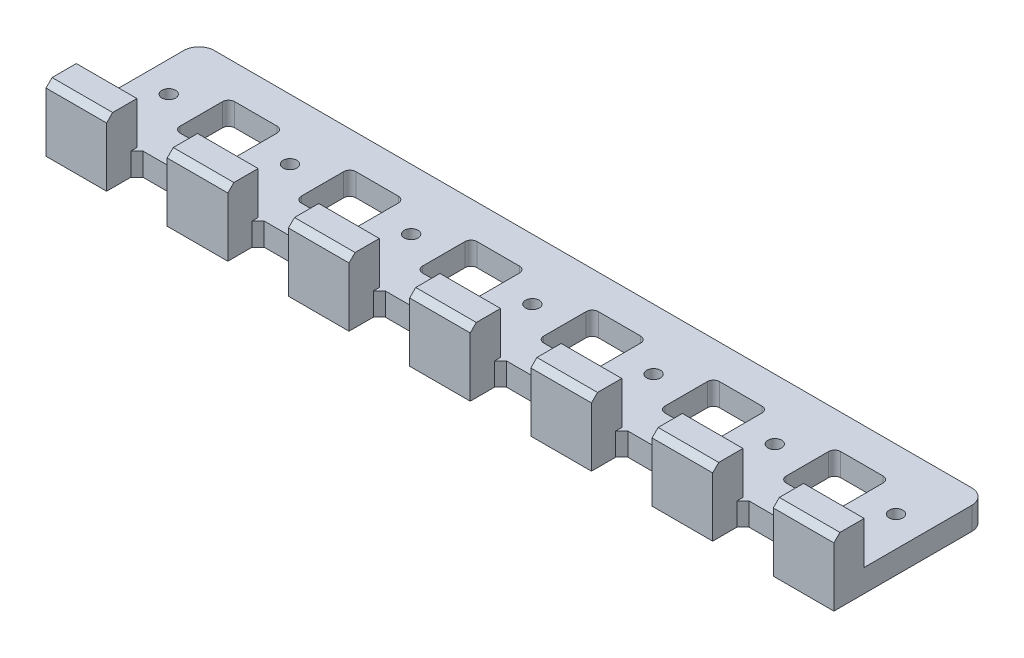
from build123d import *

# Parameters (mm, degrees)
SKETCH1_W                = 20
SKETCH1_H                = 50.5
BOSS_EXTRUDE1_DEPTH      = 7.5
SKETCH2_W                = 20
SKETCH2_H                = 10
BOSS_EXTRUDE2_DEPTH      = 14.01
LPATTERN1_COUNT          = 7
LPATTERN1_PITCH          = 40
SKETCH4_W                = 40.5
SKETCH4_H                = 7.5
BOSS_EXTRUDE3_DEPTH      = 260
M4_CLEARANCE_HOLE1_D     = 4.5
M4_CLEARANCE_HOLE1_DEPTH = 7.5
LPATTERN2_COUNT          = 7
LPATTERN2_PITCH          = 40
SKETCH7_W                = 18
SKETCH7_H                = 18
CUT_EXTRUDE1_DEPTH       = 8.5
FILLET1_R                = 2
LPATTERN3_COUNT          = 6
LPATTERN3_PITCH          = 40
FILLET1_OF_LPATTERN3_R   = 2
FILLET2_R                = 5
CHAMFER1_SIZE            = 2
CHAMFER2_SIZE            = 2


with BuildPart() as part:
    # Sketch1 → Boss-Extrude1 (new body)
    with BuildSketch(Plane(origin=(0, 0, 0), x_dir=(1, 0, 0), z_dir=(0, 1, 0))):
        with Locations((0, -25.25)):
            Rectangle(SKETCH1_W, SKETCH1_H)
    extrude(amount=BOSS_EXTRUDE1_DEPTH)

    # Sketch2 → Boss-Extrude2 (add)
    with BuildSketch(Plane(origin=(0, 7.5, 0), x_dir=(1, 0, 0), z_dir=(0, 1, 0))):
        with Locations((0, -45.5)):
            Rectangle(SKETCH2_W, SKETCH2_H)
    extrude(amount=BOSS_EXTRUDE2_DEPTH)


with BuildPart() as lpattern1_1:
    # LPattern1: pattern copy
    add(part.part.moved(Location(Vector(1, 0, 0) * (1 * LPATTERN1_PITCH))))


with BuildPart() as lpattern1_2:
    # LPattern1: pattern copy
    add(part.part.moved(Location(Vector(1, 0, 0) * (2 * LPATTERN1_PITCH))))


with BuildPart() as lpattern1_3:
    # LPattern1: pattern copy
    add(part.part.moved(Location(Vector(1, 0, 0) * (3 * LPATTERN1_PITCH))))


with BuildPart() as lpattern1_4:
    # LPattern1: pattern copy
    add(part.part.moved(Location(Vector(1, 0, 0) * (4 * LPATTERN1_PITCH))))


with BuildPart() as lpattern1_5:
    # LPattern1: pattern copy
    add(part.part.moved(Location(Vector(1, 0, 0) * (5 * LPATTERN1_PITCH))))


with BuildPart() as lpattern1_6:
    # LPattern1: pattern copy
    add(part.part.moved(Location(Vector(1, 0, 0) * (6 * LPATTERN1_PITCH))))


with BuildPart() as part_1:
    add(part.part)

    add(lpattern1_1.part)  # Boss-Extrude3 merges LPattern1_1

    add(lpattern1_2.part)  # Boss-Extrude3 merges LPattern1_2

    add(lpattern1_3.part)  # Boss-Extrude3 merges LPattern1_3

    add(lpattern1_4.part)  # Boss-Extrude3 merges LPattern1_4

    add(lpattern1_5.part)  # Boss-Extrude3 merges LPattern1_5

    add(lpattern1_6.part)  # Boss-Extrude3 merges LPattern1_6
    # Sketch4 → Boss-Extrude3 (add, through all)
    with BuildSketch(Plane.ZY.offset(10)):
        with Locations((20.25, 3.75)):
            Rectangle(SKETCH4_W, SKETCH4_H)
    extrude(amount=-BOSS_EXTRUDE3_DEPTH)

    # M4 Clearance Hole1
    with Locations(Plane.XZ):
        with Locations((240, 20)):
            m4_clearance_hole1 = Hole(M4_CLEARANCE_HOLE1_D / 2, depth=M4_CLEARANCE_HOLE1_DEPTH)

    # LPattern2: M4 Clearance Hole1 ×7
    with Locations(*[(-i * LPATTERN2_PITCH, 0, 0) for i in range(1, LPATTERN2_COUNT)]):
        add(m4_clearance_hole1, mode=Mode.SUBTRACT)

    # Sketch7 → Cut-Extrude1 (cut, through all)
    with BuildSketch(Plane(origin=(0, 7.5, 0), x_dir=(1, 0, 0), z_dir=(0, 1, 0))):
        with Locations((220, -20.25)):
            Rectangle(SKETCH7_W, SKETCH7_H)
    cut_extrude1 = extrude(amount=-CUT_EXTRUDE1_DEPTH, mode=Mode.SUBTRACT)

    # Fillet1
    fillet1_edges = [part_1.edges().sort_by_distance(p)[0] for p in [
        (229, 3.75, 11.25),
        (229, 3.75, 29.25),
        (211, 3.75, 29.25),
        (211, 3.75, 11.25),
    ]]
    fillet(fillet1_edges, radius=FILLET1_R)

    # LPattern3: Cut-Extrude1 ×6
    with Locations(*[(-i * LPATTERN3_PITCH, 0, 0) for i in range(1, LPATTERN3_COUNT)]):
        add(cut_extrude1, mode=Mode.SUBTRACT)

    # Fillet1 of LPattern3
    fillet1_of_lpattern3_edges = [part_1.edges().sort_by_distance(p)[0] for p in [
        (189, 3.75, 11.25),
        (189, 3.75, 29.25),
        (171, 3.75, 29.25),
        (171, 3.75, 11.25),
        (149, 3.75, 11.25),
        (149, 3.75, 29.25),
        (131, 3.75, 29.25),
        (131, 3.75, 11.25),
        (109, 3.75, 11.25),
        (109, 3.75, 29.25),
        (91, 3.75, 29.25),
        (91, 3.75, 11.25),
        (69, 3.75, 11.25),
        (69, 3.75, 29.25),
        (51, 3.75, 29.25),
        (51, 3.75, 11.25),
        (29, 3.75, 11.25),
        (29, 3.75, 29.25),
        (11, 3.75, 29.25),
        (11, 3.75, 11.25),
    ]]
    fillet(fillet1_of_lpattern3_edges, radius=FILLET1_OF_LPATTERN3_R)

    # Fillet2
    fillet2_edges = [part_1.edges().sort_by_distance(p)[0] for p in [
        (250, 3.75, 0),
        (-10, 3.75, 0),
    ]]
    fillet(fillet2_edges, radius=FILLET2_R)

    # Chamfer1
    chamfer1_edges = [part_1.edges().sort_by_distance(p)[0] for p in [
        (120, 21.51, 50.5),
        (160, 21.51, 50.5),
        (200, 21.51, 50.5),
        (240, 21.51, 50.5),
        (0, 21.51, 50.5),
        (40, 21.51, 50.5),
        (80, 21.51, 50.5),
    ]]
    chamfer(chamfer1_edges, length=CHAMFER1_SIZE)

    # Chamfer2
    chamfer2_edges = [part_1.edges().sort_by_distance(p)[0] for p in [
        (110, 3.75, 40.5),
        (130, 3.75, 40.5),
        (150, 3.75, 40.5),
        (170, 3.75, 40.5),
        (190, 3.75, 40.5),
        (210, 3.75, 40.5),
        (230, 3.75, 40.5),
        (10, 3.75, 40.5),
        (50, 3.75, 40.5),
        (30, 3.75, 40.5),
        (70, 3.75, 40.5),
        (90, 3.75, 40.5),
    ]]
    chamfer(chamfer2_edges, length=CHAMFER2_SIZE)


solid = part_1.part
